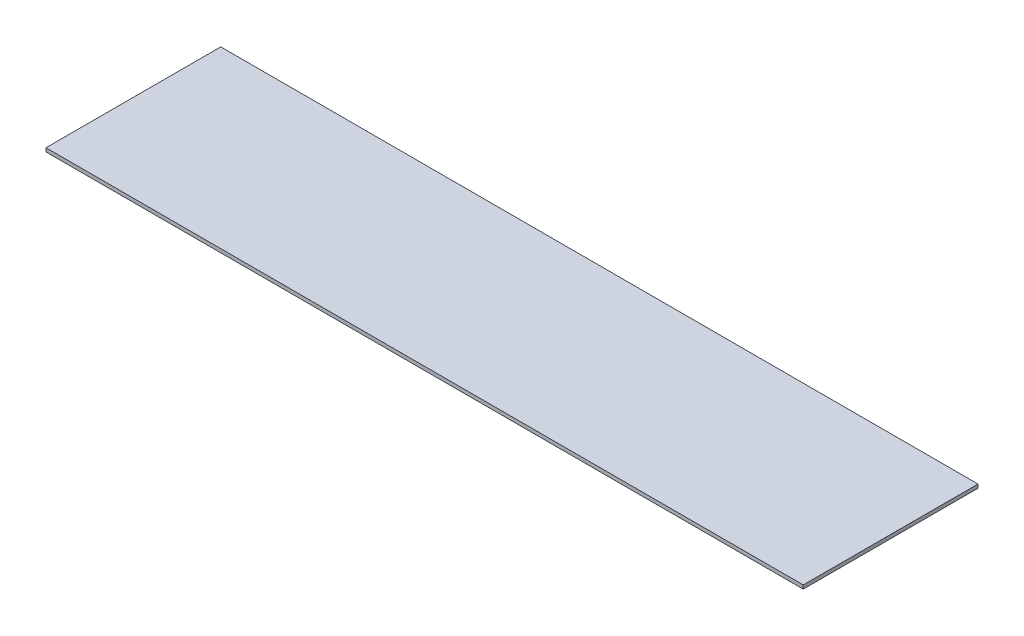
from build123d import *

# Parameters (mm, degrees)
CROQUIS1_W              = 416
CROQUIS1_H              = 96
SALIENTE_EXTRUIR1_DEPTH = 2


with BuildPart() as part:
    # Croquis1 → Saliente-Extruir1 (new body)
    with BuildSketch(Plane(origin=(0, 0, 0), x_dir=(1, 0, 0), z_dir=(0, 1, 0))):
        Rectangle(CROQUIS1_W, CROQUIS1_H)
    extrude(amount=SALIENTE_EXTRUIR1_DEPTH)


solid = part.part
